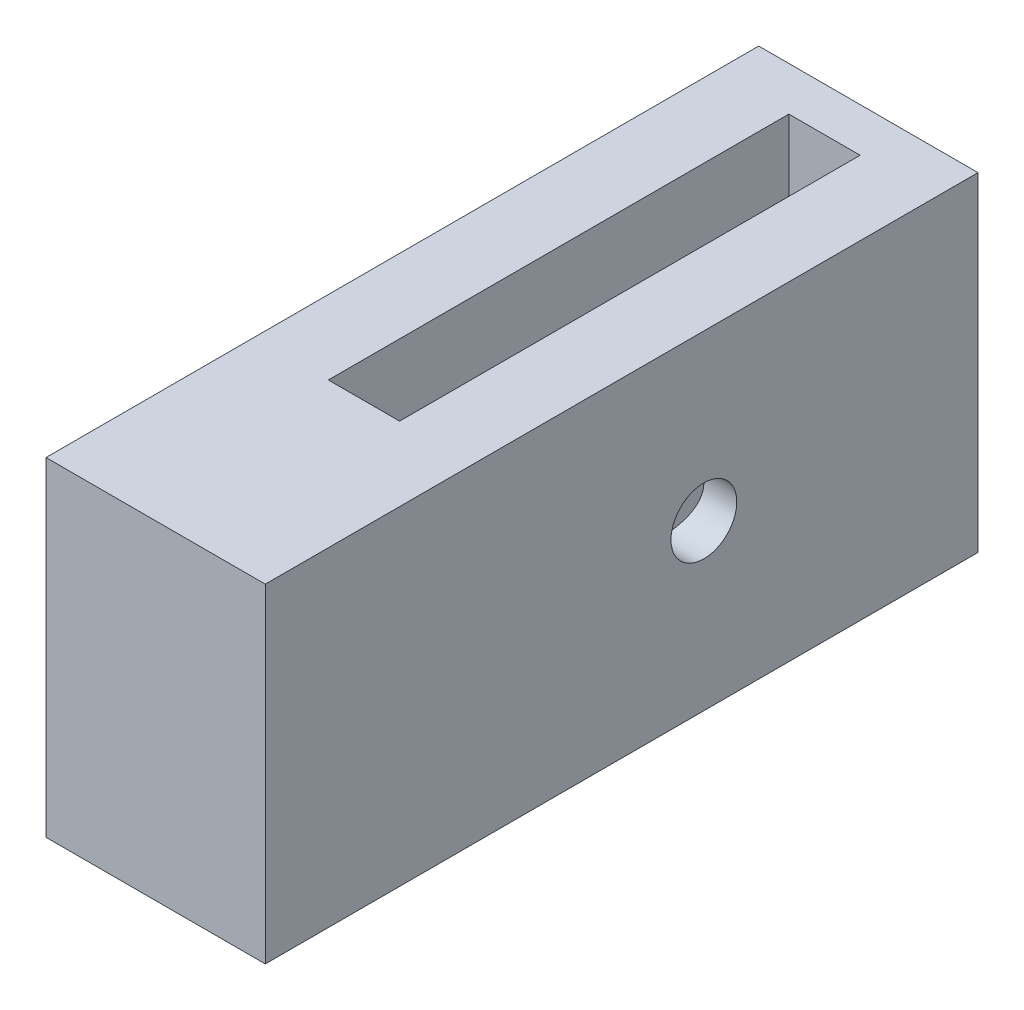
from build123d import *

# Parameters (mm, degrees)
SKETCH1_W           = 20
SKETCH1_H           = 30
BOSS_EXTRUDE1_DEPTH = 65
SKETCH3_R           = 7
CUT_EXTRUDE1_DEPTH  = 60
SKETCH4_R           = 3
CUT_EXTRUDE2_DEPTH  = 21
SKETCH5_W           = 6.5
SKETCH5_H           = 42
CUT_EXTRUDE3_DEPTH  = 31


with BuildPart() as part:
    # Sketch1 → Boss-Extrude1 (new body)
    with BuildSketch(Plane.XY):
        Rectangle(SKETCH1_W, SKETCH1_H)
    extrude(amount=BOSS_EXTRUDE1_DEPTH)

    # Sketch3 → Cut-Extrude1 (cut)
    with BuildSketch(Plane.XY):
        Circle(SKETCH3_R)
    extrude(amount=CUT_EXTRUDE1_DEPTH, mode=Mode.SUBTRACT)

    # Sketch4 → Cut-Extrude2 (cut, through all)
    with BuildSketch(Plane.ZY.offset(10)):
        with Locations((25, 0)):
            Circle(SKETCH4_R)
    extrude(amount=-CUT_EXTRUDE2_DEPTH, mode=Mode.SUBTRACT)

    # Sketch5 → Cut-Extrude3 (cut, through all)
    with BuildSketch(Plane(origin=(0, 15, 0), x_dir=(1, 0, 0), z_dir=(0, 1, 0))):
        with Locations((0, -25)):
            Rectangle(SKETCH5_W, SKETCH5_H)
    extrude(amount=-CUT_EXTRUDE3_DEPTH, mode=Mode.SUBTRACT)


solid = part.part
